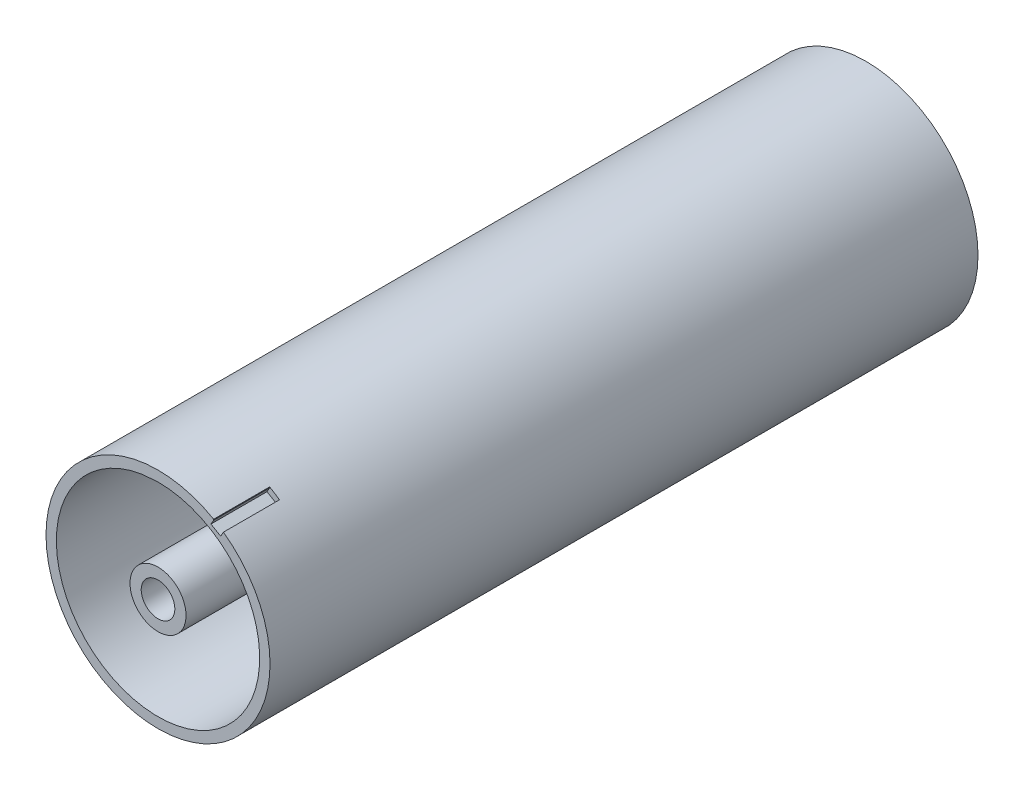
from build123d import *

# Parameters (mm, degrees)
SKETCH_2_R          = 20
SKETCH_2_R_2        = 18.15
EXTRUDE_1_DEPTH     = 126.4
SKETCH_5_R          = 3
EXTRUDE_3_DEPTH     = 126.4
CUT_EXTRUDE1_DEPTH  = 59
CUT_EXTRUDE2_DEPTH  = 59
SKETCH3_R           = 5
SKETCH3_R_2         = 3
BOSS_EXTRUDE1_DEPTH = 58.6
CUT_EXTRUDE3_DEPTH  = 10


with BuildPart() as part:
    # Эскиз2 → Бобышка-Вытянуть1 (new body)
    with BuildSketch(Plane.XY):
        Circle(SKETCH_2_R)
        Circle(SKETCH_2_R_2, mode=Mode.SUBTRACT)
    extrude(amount=EXTRUDE_1_DEPTH)

    # Эскиз5 → Бобышка-Вытянуть3 (add, through all)
    with BuildSketch(Plane(origin=(0, 0, 0), x_dir=(-1, 0, 0), z_dir=(0, 0, -1))):
        with BuildLine():
            Line((0, 18.15), (0, 9.219544457))
            ThreePointArc((0, 9.219544457), (-0.725705562, 6.35915669), (-2.727272727, 4.190702026))
            ThreePointArc((-2.727272727, 4.190702026), (-0.41322314, -4.982895407), (3.380325874, 3.68420914))
            ThreePointArc((3.380325874, 3.68420914), (1.76329678, 6.152747909), (1.518678537, 9.093602999))
            Line((1.518678537, 9.093602999), (2.989737244, 17.902066116))
            ThreePointArc((2.989737244, 17.902066116), (1.5, 18.087910327), (0, 18.15))
        make_face()
        Circle(SKETCH_5_R, mode=Mode.SUBTRACT)
    extrude(amount=-EXTRUDE_3_DEPTH)

    # Sketch1 → Cut-Extrude1 (cut)
    with BuildSketch(Plane(origin=(0, 0, 0), x_dir=(-1, 0, 0), z_dir=(0, 0, -1))):
        with BuildLine():
            Line((0, 18.15), (2.989737244, 17.902066116))
            ThreePointArc((2.989737244, 17.902066116), (-1.5, -18.087910327), (0, 18.15))
        make_face()
    extrude(amount=-CUT_EXTRUDE1_DEPTH, mode=Mode.SUBTRACT)

    # Sketch2 → Cut-Extrude2 (cut)
    with BuildSketch(Plane.XY.offset(126.4)):
        with BuildLine():
            Line((0, 18.15), (-2.989737244, 17.902066116))
            ThreePointArc((-2.989737244, 17.902066116), (1.5, -18.087910327), (0, 18.15))
        make_face()
    extrude(amount=-CUT_EXTRUDE2_DEPTH, mode=Mode.SUBTRACT)

    # Sketch4 → Cut-Extrude3 (cut)
    with BuildSketch(Plane.XY.offset(126.4)):
        with BuildLine():
            Line((9.949874371, 17.23368794), (9.449874371, 16.367662536))
            Line((9.449874371, 16.367662536), (11.181925179, 15.367662536))
            Line((11.181925179, 15.367662536), (11.681925179, 16.23368794))
            ThreePointArc((11.681925179, 16.23368794), (11.905777201, 18.621411015), (9.949874371, 17.23368794))
        make_face()
    extrude(amount=-CUT_EXTRUDE3_DEPTH, mode=Mode.SUBTRACT)


with BuildPart() as body_2:
    # Sketch3 → Boss-Extrude1 (new body)
    with BuildSketch(Plane.XY.offset(126.4)):
        Circle(SKETCH3_R)
        Circle(SKETCH3_R_2, mode=Mode.SUBTRACT)
    extrude(amount=-BOSS_EXTRUDE1_DEPTH)


solid = Compound([part.part, body_2.part])
